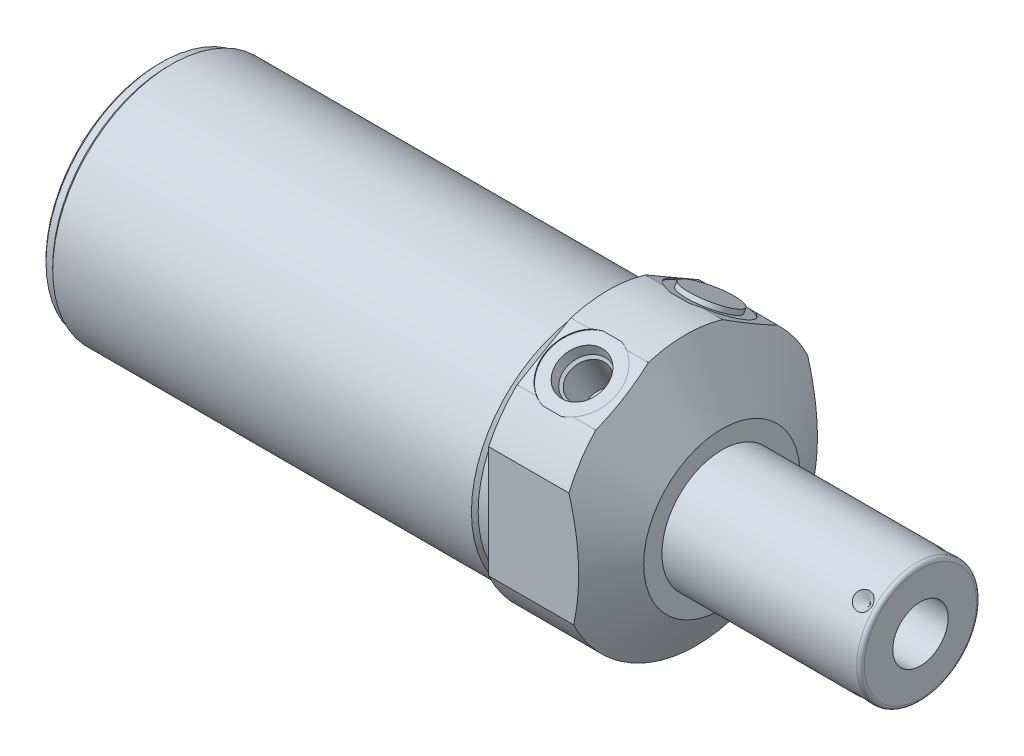
from build123d import *

# Parameters (mm, degrees)
SKETCH1_R           = 34.925
EXTRUDE1_DEPTH      = 30.1498
EXTRUDE1_DEPTH_BACK = 119.0752
CUT_EXTRUDE1_REACH  = 121.075
SKETCH2_R           = 34.925
SKETCH2_R_2         = 31.496
CUT_EXTRUDE3_START  = -30.1498
SKETCH4_R           = 41.275
CUT_EXTRUDE3_DEPTH  = 30.1498
SKETCH18_R          = 9.525
CUT_EXTRUDE4_DEPTH  = 0.254
SKETCH19_R          = 9.525
CUT_EXTRUDE5_DEPTH  = 0.254
CHAMFER1_SIZE       = 0.762
SKETCH15_R          = 6.9469
EXTRUDE2_DEPTH      = 1.27
CIRPATTERN1_COUNT   = 4


with BuildPart() as part:
    # Sketch1 → Extrude1 (new body, two sides)
    with BuildSketch(Plane(origin=(0, 0, 0), x_dir=(0, 0, -1), z_dir=(1, 0, 0))) as extrude1_sk:
        Circle(SKETCH1_R)
    extrude(amount=EXTRUDE1_DEPTH)
    extrude(extrude1_sk.sketch, amount=-EXTRUDE1_DEPTH_BACK)

    # Sketch2 → Cut-Extrude1 (cut, up to next)
    with BuildSketch(Plane(origin=(0, 0, 0), x_dir=(0, 0, -1), z_dir=(1, 0, 0)), mode=Mode.PRIVATE) as cut_extrude1_sk1:
        Circle(SKETCH2_R)
        with Locations((0, -2.54)):
            Circle(SKETCH2_R_2, mode=Mode.SUBTRACT)
    cut_extrude1_tool1 = extrude(cut_extrude1_sk1.sketch, amount=-CUT_EXTRUDE1_REACH, mode=Mode.PRIVATE) & part.part
    add(cut_extrude1_tool1.solids().sort_by_distance((0, 0, 33.937172))[0], mode=Mode.SUBTRACT)

    # Sketch4 → Cut-Extrude3 (cut)
    with BuildSketch(Plane.ZY.offset(CUT_EXTRUDE3_START)):
        Circle(SKETCH4_R)
        with BuildLine():
            Line((31.623, -14.823680245), (31.623, 20.938179637))
            Line((31.623, 20.938179637), (0, 39.195727199))
            Line((0, 39.195727199), (-31.623, 20.938179637))
            Line((-31.623, 20.938179637), (-31.623, -14.823680245))
            ThreePointArc((-31.623, -14.823680245), (0, -34.925), (31.623, -14.823680245))
        make_face(mode=Mode.SUBTRACT)
    extrude(amount=CUT_EXTRUDE3_DEPTH, mode=Mode.SUBTRACT)

    # Sketch6 → Cut-Revolve2 (revolve, cut)
    with BuildSketch(Plane.XY, mode=Mode.PRIVATE) as cut_revolve2_sk:
        Polygon((0.307141936, 69.85), (30.1498, 18.161), (30.1498, 69.85), align=None)
    revolve(cut_revolve2_sk.sketch.rotate(Axis((-1.184990967, -2.54, 0), (1, 0, 0)), 270), axis=Axis((-1.184990967, -2.54, 0), (1, 0, 0)), mode=Mode.SUBTRACT)  # turned: the seam where the file's is

    # S2D0002 → Cut-Revolve3 (revolve, cut)
    with BuildSketch(Plane(origin=(9.9568, 29.176824947, 16.845247737), x_dir=(0, 0.5, -0.866025404), z_dir=(1, 0, 0))):
        Polygon((0, 0), (6.1849, 0), (5.642306865, -2.5527), (4.9784, -3.216606865), (4.9784, -13.462), (0, -13.462), align=None)
    revolve(axis=Axis((9.9568, 16.935469262, 9.777697737), (0, 0.866025404, 0.5)), mode=Mode.SUBTRACT)

    # Sketch8 → Cut-Revolve4 (revolve, cut)
    with BuildSketch(Plane(origin=(9.9568, 29.176824947, -16.845247737), x_dir=(0, -0.5, -0.866025404), z_dir=(1, 0, 0))):
        Polygon((0, 0), (6.1849, 0), (5.642306865, -2.5527), (4.9784, -3.216606865), (4.9784, -13.462), (0, -13.462), align=None)
    revolve(axis=Axis((9.9568, 16.935469262, -9.777697737), (0, 0.866025404, -0.5)), mode=Mode.SUBTRACT)

    # Sketch18 → Cut-Extrude4 (cut)
    with BuildSketch(Plane(origin=(0, 29.396795399, 16.972247737), x_dir=(1, 0, 0), z_dir=(0, 0.866025404, 0.5))):
        with Locations((9.9568, 0)):
            Circle(SKETCH18_R)
    extrude(amount=-CUT_EXTRUDE4_DEPTH, mode=Mode.SUBTRACT)

    # Sketch19 → Cut-Extrude5 (cut)
    with BuildSketch(Plane(origin=(0, 29.396795399, -16.972247737), x_dir=(1, 0, 0), z_dir=(0, 0.866025404, -0.5))):
        with Locations((9.9568, 0)):
            Circle(SKETCH19_R)
    extrude(amount=-CUT_EXTRUDE5_DEPTH, mode=Mode.SUBTRACT)

    # Sketch10 → Cut-Revolve6 (revolve, cut)
    with BuildSketch(Plane.XY, mode=Mode.PRIVATE) as cut_revolve6_sk:
        Polygon((0, 28.956), (0, 28.067), (-3.81, 28.067), (-4.699, 28.956), align=None)
    revolve(cut_revolve6_sk.sketch.rotate(Axis((-4.93395, -2.54, 0), (1, 0, 0)), 90), axis=Axis((-4.93395, -2.54, 0), (1, 0, 0)), mode=Mode.SUBTRACT)  # turned: the seam where the file's is

    # Sketch12 → Cut-Revolve8 (revolve, cut)
    with BuildSketch(Plane.XY, mode=Mode.PRIVATE) as cut_revolve8_sk:
        Polygon((-119.0752, 28.956), (-119.0752, 28.067), (-116.5352, 28.067), (-115.6462, 28.956), align=None)
    revolve(cut_revolve8_sk.sketch.rotate(Axis((-119.24665, -2.54, 0), (1, 0, 0)), 90), axis=Axis((-119.24665, -2.54, 0), (1, 0, 0)), mode=Mode.SUBTRACT)  # turned: the seam where the file's is

    # Chamfer1
    chamfer1_edges = [part.edges().sort_by_distance(p)[0] for p in [
        (-119.0752, -2.54, -30.607),
    ]]
    chamfer(chamfer1_edges, length=CHAMFER1_SIZE)

    # Sketch13 → Revolve1 (revolve)
    with BuildSketch(Plane(origin=(0, 0, 0), x_dir=(0, -1, 0), z_dir=(0, 0, 1)), mode=Mode.PRIVATE) as revolve1_sk:
        with BuildLine():
            Line((2.54, 30.1498), (2.54, 82.7786))
            Line((2.54, 82.7786), (17.399, 82.7786))
            ThreePointArc((17.399, 82.7786), (18.11742049, 82.48102049), (18.415, 81.7626))
            Line((18.415, 81.7626), (18.415, 30.1498))
            Line((18.415, 30.1498), (2.54, 30.1498))
        make_face()
    revolve(revolve1_sk.sketch.rotate(Axis((27.51836, -2.54, 0), (1, 0, 0)), 270), axis=Axis((27.51836, -2.54, 0), (1, 0, 0)))  # turned: the seam where the file's is

    # S2D0001 → Cut-Revolve9 (revolve, cut)
    with BuildSketch(Plane(origin=(82.7786, -9.8806, 0), x_dir=(0, -1, 0), z_dir=(0, 0, 1)), mode=Mode.PRIVATE) as cut_revolve9_sk:
        Polygon((0, 0), (0, -25.4), (-7.3406, -29.81067746), (-7.3406, 0), align=None)
    revolve(cut_revolve9_sk.sketch.rotate(Axis((51.477388667, -2.54, 0), (1, 0, 0)), 270), axis=Axis((51.477388667, -2.54, 0), (1, 0, 0)), mode=Mode.SUBTRACT)  # turned: the seam where the file's is

    # Sketch15 → Extrude2 (add)
    with BuildSketch(Plane(origin=(30.1498, 29.176824947, -16.845247737), x_dir=(0, -0.5, -0.866025404), z_dir=(0, -0.866025404, 0.5))):
        with Locations((0, -20.193)):
            Circle(SKETCH15_R)
    extrude(amount=-EXTRUDE2_DEPTH)

    # Sketch16 → Cut-Revolve10 (revolve, cut)
    with BuildSketch(Plane(origin=(78.8162, 8.685320151, -11.225320151), x_dir=(-1, 0, 0), z_dir=(0, -0.707106781, -0.707106781)), mode=Mode.PRIVATE) as cut_revolve10_sk:
        Polygon((0, 0), (2.413, 0), (0, -2.413), align=None)
    cut_revolve10 = revolve(cut_revolve10_sk.sketch.rotate(Axis((78.8162, 6.893759055, -9.433759055), (0, 0.707106781, -0.707106781)), 90), axis=Axis((78.8162, 6.893759055, -9.433759055), (0, 0.707106781, -0.707106781)), mode=Mode.SUBTRACT)  # turned: the seam where the file's is

    # CirPattern1: Cut-Revolve10 ×4 about axis
    cirpattern1_axis = Axis((27.51836, -2.54, 0), (-1, 0, 0))
    for i in range(1, CIRPATTERN1_COUNT):
        add(cut_revolve10.rotate(cirpattern1_axis, i * 360 / CIRPATTERN1_COUNT), mode=Mode.SUBTRACT)


solid = part.part
